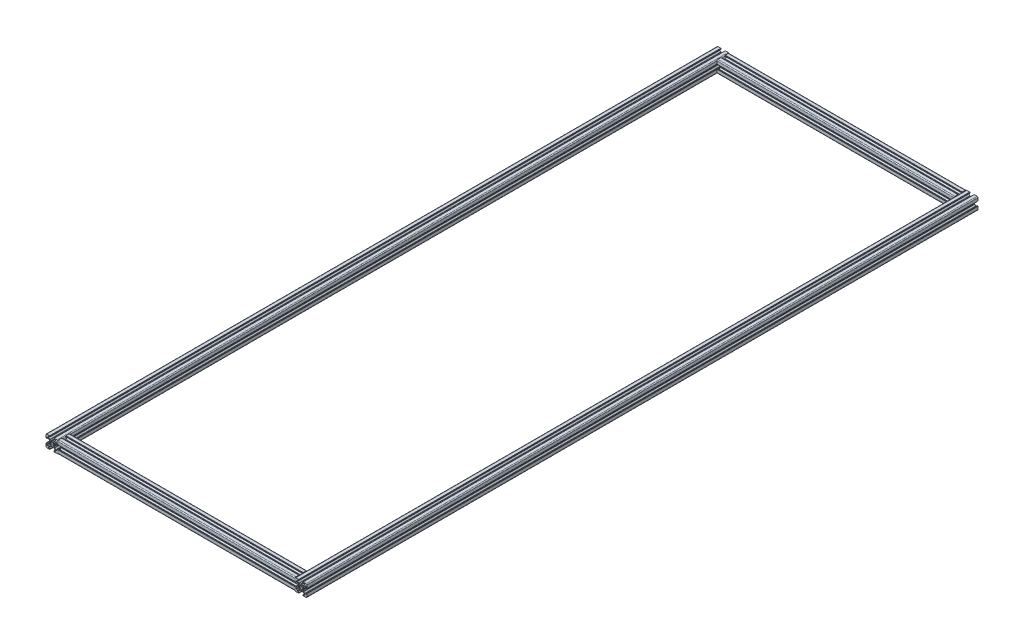
from build123d import *

# Parameters (mm, degrees)
T_SLOT_20X20_1_DEPTH   = 1125
T_SLOT_20X20_1_2_DEPTH = 1125
T_SLOT_20X20_2_DEPTH   = 397.401314794
T_SLOT_20X20_3_DEPTH   = 397.497051185


with BuildPart() as part:
    # Sketch11 → T-slot 20X20(1) (new body)
    with BuildSketch(Plane(origin=(0, 0, 491.029411765), x_dir=(-1, 0, 0), z_dir=(0, 0, -1))):
        with BuildLine():
            Line((5.499785909, -8.498545991), (3.499785223, -8.498545991))
            ThreePointArc((3.499785223, -8.498545991), (3.146231832, -8.644992601), (2.999785223, -8.998545991))
            Line((2.999785223, -8.998545991), (2.999785223, -9.298545991))
            ThreePointArc((2.999785223, -9.298545991), (3.058363866, -9.439967347), (3.199785223, -9.498545991))
            Line((3.199785223, -9.498545991), (3.348917703, -9.498545991))
            ThreePointArc((3.348917703, -9.498545991), (3.490339059, -9.557124635), (3.548917703, -9.698545991))
            Line((3.548917703, -9.698545991), (3.548917703, -9.798898698))
            ThreePointArc((3.548917703, -9.798898698), (3.607496347, -9.940320055), (3.748917703, -9.998898698))
            Line((3.748917703, -9.998898698), (8.50021851, -9.998898698))
            ThreePointArc((8.50021851, -9.998898698), (9.560878681, -9.55955887), (10.00021851, -8.498898698))
            Line((10.00021851, -8.498898698), (10.00021851, -3.748917703))
            ThreePointArc((10.00021851, -3.748917703), (9.941639866, -3.607496347), (9.80021851, -3.548917703))
            Line((9.80021851, -3.548917703), (9.699407618, -3.548917703))
            ThreePointArc((9.699407618, -3.548917703), (9.557986262, -3.490339059), (9.499407618, -3.348917703))
            Line((9.499407618, -3.348917703), (9.499407618, -3.198545506))
            ThreePointArc((9.499407618, -3.198545506), (9.440828975, -3.05712415), (9.299407618, -2.998545506))
            Line((9.299407618, -2.998545506), (8.999407619, -2.998545506))
            ThreePointArc((8.999407619, -2.998545506), (8.645854228, -3.144992116), (8.499407619, -3.498545506))
            Line((8.499407619, -3.498545506), (8.499407619, -5.498575296))
            ThreePointArc((8.499407619, -5.498575296), (8.352961009, -5.852128686), (7.999407619, -5.998575295))
            Line((7.999407619, -5.998575295), (7.267164191, -5.998575295))
            ThreePointArc((7.267164191, -5.998575295), (7.075822118, -5.960514914), (6.913610254, -5.85212814))
            Line((6.913610254, -5.85212814), (4.64584686, -3.584357742))
            ThreePointArc((4.64584686, -3.584357742), (4.537460883, -3.422146257), (4.499400797, -3.230804897))
            Line((4.499400797, -3.230804897), (4.499400797, -0.952160718))
            ThreePointArc((4.499400797, -0.952160718), (4.492585963, -0.900396911), (4.47260588, -0.852160722))
            Line((4.47260588, -0.852160722), (4.037520883, -0.09857136))
            ThreePointArc((4.037520883, -0.09857136), (4.010725966, 0.001428635), (4.037520883, 0.101428631))
            Line((4.037520883, 0.101428631), (4.47260588, 0.855018004))
            ThreePointArc((4.47260588, 0.855018004), (4.492585963, 0.903254193), (4.499400797, 0.955017999))
            Line((4.499400797, 0.955017999), (4.499400797, 3.233299817))
            ThreePointArc((4.499400797, 3.233299817), (4.537461178, 3.42464189), (4.645847952, 3.586853754))
            Line((4.645847952, 3.586853754), (6.91361835, 5.854617148))
            ThreePointArc((6.91361835, 5.854617148), (7.075829835, 5.963003125), (7.267171195, 6.001063211))
            Line((7.267171195, 6.001063211), (7.999407619, 6.001063211))
            ThreePointArc((7.999407619, 6.001063211), (8.352961009, 5.854616602), (8.499407619, 5.501063211))
            Line((8.499407619, 5.501063211), (8.499407619, 3.500665018))
            ThreePointArc((8.499407619, 3.500665018), (8.645854228, 3.147111627), (8.999407619, 3.000665018))
            Line((8.999407619, 3.000665018), (9.299407618, 3.000665018))
            ThreePointArc((9.299407618, 3.000665018), (9.440828975, 3.059243661), (9.499407618, 3.200665018))
            Line((9.499407618, 3.200665018), (9.499407618, 3.348917703))
            ThreePointArc((9.499407618, 3.348917703), (9.557986262, 3.490339059), (9.699407618, 3.548917703))
            Line((9.699407618, 3.548917703), (9.80021851, 3.548917703))
            ThreePointArc((9.80021851, 3.548917703), (9.941639866, 3.607496347), (10.00021851, 3.748917703))
            Line((10.00021851, 3.748917703), (10.00021851, 8.498918098))
            ThreePointArc((10.00021851, 8.498918098), (9.560878681, 9.55957827), (8.50021851, 9.998918098))
            Line((8.50021851, 9.998918098), (3.748917703, 9.998918098))
            ThreePointArc((3.748917703, 9.998918098), (3.607496347, 9.940339455), (3.548917703, 9.798918098))
            Line((3.548917703, 9.798918098), (3.548917703, 9.701076618))
            ThreePointArc((3.548917703, 9.701076618), (3.490339059, 9.559655262), (3.348917703, 9.501076618))
            Line((3.348917703, 9.501076618), (3.199785223, 9.501076618))
            ThreePointArc((3.199785223, 9.501076618), (3.058363866, 9.442497974), (2.999785223, 9.301076618))
            Line((2.999785223, 9.301076618), (2.999785223, 9.001076618))
            ThreePointArc((2.999785223, 9.001076618), (3.146231832, 8.647523228), (3.499785223, 8.501076618))
            Line((3.499785223, 8.501076618), (5.499785909, 8.501076618))
            ThreePointArc((5.499785909, 8.501076618), (5.853339299, 8.354630009), (5.999785909, 8.001076618))
            Line((5.999785909, 8.001076618), (5.999785909, 7.269203309))
            ThreePointArc((5.999785909, 7.269203309), (5.961725527, 7.077861236), (5.853338753, 6.915649372))
            Line((5.853338753, 6.915649372), (3.585209085, 4.647526709))
            ThreePointArc((3.585209085, 4.647526709), (3.4229976, 4.539140732), (3.231656241, 4.501080646))
            Line((3.231656241, 4.501080646), (0.953012714, 4.501080646))
            ThreePointArc((0.953012714, 4.501080646), (0.901248907, 4.494265812), (0.853012718, 4.474285729))
            Line((0.853012718, 4.474285729), (0.099422452, 4.03920021))
            ThreePointArc((0.099422452, 4.03920021), (-0.000577544, 4.012405293), (-0.100577539, 4.03920021))
            Line((-0.100577539, 4.03920021), (-0.854167817, 4.47428573))
            ThreePointArc((-0.854167817, 4.47428573), (-0.902404006, 4.494265812), (-0.954167812, 4.501080646))
            Line((-0.954167812, 4.501080646), (-3.232459322, 4.501080646))
            ThreePointArc((-3.232459322, 4.501080646), (-3.423801395, 4.539141027), (-3.586013258, 4.647527801))
            Line((-3.586013258, 4.647527801), (-5.854146074, 6.915667622))
            ThreePointArc((-5.854146074, 6.915667622), (-5.962532052, 7.077879107), (-6.000592138, 7.269220467))
            Line((-6.000592138, 7.269220467), (-6.000592138, 8.001076618))
            ThreePointArc((-6.000592138, 8.001076618), (-5.854145528, 8.354630009), (-5.500592138, 8.501076618))
            Line((-5.500592138, 8.501076618), (-3.500232358, 8.501076618))
            ThreePointArc((-3.500232358, 8.501076618), (-3.146678968, 8.647523228), (-3.000232358, 9.001076618))
            Line((-3.000232358, 9.001076618), (-3.000232358, 9.301076618))
            ThreePointArc((-3.000232358, 9.301076618), (-3.058811002, 9.442497974), (-3.200232358, 9.501076618))
            Line((-3.200232358, 9.501076618), (-3.348917703, 9.501076618))
            ThreePointArc((-3.348917703, 9.501076618), (-3.490339059, 9.559655262), (-3.548917703, 9.701076618))
            Line((-3.548917703, 9.701076618), (-3.548917703, 9.798918098))
            ThreePointArc((-3.548917703, 9.798918098), (-3.607496347, 9.940339455), (-3.748917703, 9.998918098))
            Line((-3.748917703, 9.998918098), (-8.498466696, 9.998918098))
            ThreePointArc((-8.498466696, 9.998918098), (-9.559126868, 9.55957827), (-9.998466696, 8.498918098))
            Line((-9.998466696, 8.498918098), (-9.998466696, 3.748917703))
            ThreePointArc((-9.998466696, 3.748917703), (-9.939888052, 3.607496347), (-9.798466696, 3.548917703))
            Line((-9.798466696, 3.548917703), (-9.699890154, 3.548917703))
            ThreePointArc((-9.699890154, 3.548917703), (-9.558468798, 3.490339059), (-9.499890154, 3.348917703))
            Line((-9.499890154, 3.348917703), (-9.499890154, 3.200665018))
            ThreePointArc((-9.499890154, 3.200665018), (-9.441311511, 3.059243661), (-9.299890154, 3.000665018))
            Line((-9.299890154, 3.000665018), (-8.999890154, 3.000665018))
            ThreePointArc((-8.999890154, 3.000665018), (-8.646336764, 3.147111627), (-8.499890154, 3.500665018))
            Line((-8.499890154, 3.500665018), (-8.499890154, 5.501063211))
            ThreePointArc((-8.499890154, 5.501063211), (-8.353443545, 5.854616602), (-7.999890154, 6.001063211))
            Line((-7.999890154, 6.001063211), (-7.26792762, 6.001063211))
            ThreePointArc((-7.26792762, 6.001063211), (-7.076585548, 5.96300283), (-6.914373684, 5.854616056))
            Line((-6.914373684, 5.854616056), (-4.646707794, 3.586943162))
            ThreePointArc((-4.646707794, 3.586943162), (-4.538321817, 3.424731677), (-4.500261731, 3.233390317))
            Line((-4.500261731, 3.233390317), (-4.500261731, 0.955009441))
            ThreePointArc((-4.500261731, 0.955009441), (-4.493446896, 0.903245635), (-4.473466814, 0.855009445))
            Line((-4.473466814, 0.855009445), (-4.03838182, 0.101420088))
            ThreePointArc((-4.03838182, 0.101420088), (-4.011586903, 0.001420093), (-4.038381819, -0.098579903))
            Line((-4.038381819, -0.098579903), (-4.473466814, -0.852169272))
            ThreePointArc((-4.473466814, -0.852169272), (-4.493446897, -0.90040546), (-4.500261731, -0.952169266))
            Line((-4.500261731, -0.952169266), (-4.500261731, -3.230811901))
            ThreePointArc((-4.500261731, -3.230811901), (-4.538322112, -3.422153974), (-4.646708886, -3.584365838))
            Line((-4.646708886, -3.584365838), (-6.914479284, -5.852129232))
            ThreePointArc((-6.914479284, -5.852129232), (-7.076690769, -5.960515209), (-7.268032129, -5.998575295))
            Line((-7.268032129, -5.998575295), (-7.999890154, -5.998575295))
            ThreePointArc((-7.999890154, -5.998575295), (-8.353443545, -5.852128686), (-8.499890154, -5.498575295))
            Line((-8.499890154, -5.498575295), (-8.499890154, -3.498545506))
            ThreePointArc((-8.499890154, -3.498545506), (-8.646336764, -3.144992116), (-8.999890154, -2.998545506))
            Line((-8.999890154, -2.998545506), (-9.299890154, -2.998545506))
            ThreePointArc((-9.299890154, -2.998545506), (-9.441311511, -3.05712415), (-9.499890154, -3.198545506))
            Line((-9.499890154, -3.198545506), (-9.499890154, -3.348917703))
            ThreePointArc((-9.499890154, -3.348917703), (-9.558468798, -3.490339059), (-9.699890154, -3.548917703))
            Line((-9.699890154, -3.548917703), (-9.798466696, -3.548917703))
            ThreePointArc((-9.798466696, -3.548917703), (-9.939888052, -3.607496347), (-9.998466696, -3.748917703))
            Line((-9.998466696, -3.748917703), (-9.998466696, -8.498898698))
            ThreePointArc((-9.998466696, -8.498898698), (-9.559126868, -9.55955887), (-8.498466696, -9.998898698))
            Line((-8.498466696, -9.998898698), (-3.748917703, -9.998898698))
            ThreePointArc((-3.748917703, -9.998898698), (-3.607496347, -9.940320055), (-3.548917703, -9.798898698))
            Line((-3.548917703, -9.798898698), (-3.548917703, -9.698545991))
            ThreePointArc((-3.548917703, -9.698545991), (-3.490339059, -9.557124635), (-3.348917703, -9.498545991))
            Line((-3.348917703, -9.498545991), (-3.200232358, -9.498545991))
            ThreePointArc((-3.200232358, -9.498545991), (-3.058811002, -9.439967347), (-3.000232358, -9.298545991))
            Line((-3.000232358, -9.298545991), (-3.000232358, -8.998545991))
            ThreePointArc((-3.000232358, -8.998545991), (-3.146678968, -8.644992601), (-3.500232358, -8.498545991))
            Line((-3.500232358, -8.498545991), (-5.500592138, -8.498545991))
            ThreePointArc((-5.500592138, -8.498545991), (-5.854145528, -8.352099382), (-6.000592138, -7.998545991))
            Line((-6.000592138, -7.998545991), (-6.000592138, -7.266660688))
            ThreePointArc((-6.000592138, -7.266660688), (-5.962531756, -7.075318615), (-5.854144982, -6.913106751))
            Line((-5.854144982, -6.913106751), (-3.58639624, -4.645365013))
            ThreePointArc((-3.58639624, -4.645365013), (-3.424184755, -4.536979036), (-3.232843395, -4.49891895))
            Line((-3.232843395, -4.49891895), (-0.954199096, -4.49891895))
            ThreePointArc((-0.954199096, -4.49891895), (-0.90243529, -4.492104116), (-0.854199101, -4.472124033))
            Line((-0.854199101, -4.472124033), (-0.100608835, -4.037038514))
            ThreePointArc((-0.100608835, -4.037038514), (-0.00060884, -4.010243598), (0.099391156, -4.037038514))
            Line((0.099391156, -4.037038514), (0.852981433, -4.472124033))
            ThreePointArc((0.852981433, -4.472124033), (0.901217622, -4.492104116), (0.952981428, -4.49891895))
            Line((0.952981428, -4.49891895), (3.232022111, -4.49891895))
            ThreePointArc((3.232022111, -4.49891895), (3.423364184, -4.536979331), (3.585576047, -4.645366105))
            Line((3.585576047, -4.645366105), (5.853339845, -6.913136907))
            ThreePointArc((5.853339845, -6.913136907), (5.961725823, -7.075348392), (5.999785909, -7.266689752))
            Line((5.999785909, -7.266689752), (5.999785909, -7.998545991))
            ThreePointArc((5.999785909, -7.998545991), (5.853339299, -8.352099382), (5.499785909, -8.498545991))
        make_face()
        with BuildLine():
            Line((2.99144723, 1.909465981), (2.444531068, 1.257791687))
            ThreePointArc((2.444531068, 1.257791687), (2.749140242, -3.06e-07), (2.444530789, -1.257792231))
            Line((2.444530789, -1.257792231), (2.991447018, -1.909466314))
            ThreePointArc((2.991447018, -1.909466314), (2.511126206, -2.50780024), (1.913429408, -2.988913643))
            Line((1.913429408, -2.988913643), (1.257791806, -2.444531007))
            ThreePointArc((1.257791806, -2.444531007), (-3.06e-07, -2.749140242), (-1.25779235, -2.444530727))
            Line((-1.25779235, -2.444530727), (-1.913495818, -2.988871128))
            ThreePointArc((-1.913495818, -2.988871128), (-2.511154205, -2.507772203), (-2.99144723, -1.909465981))
            Line((-2.99144723, -1.909465981), (-2.444531068, -1.257791687))
            ThreePointArc((-2.444531068, -1.257791687), (-2.749140242, 3.06e-07), (-2.444530789, 1.257792231))
            Line((-2.444530789, 1.257792231), (-2.991447018, 1.909466314))
            ThreePointArc((-2.991447018, 1.909466314), (-2.511126206, 2.50780024), (-1.913429408, 2.988913643))
            Line((-1.913429408, 2.988913643), (-1.257791806, 2.444531007))
            ThreePointArc((-1.257791806, 2.444531007), (-4.0323e-05, 2.749140242), (1.257720096, 2.444567903))
            Line((1.257720096, 2.444567903), (1.91342974, 2.98891343))
            ThreePointArc((1.91342974, 2.98891343), (2.511126484, 2.507799961), (2.99144723, 1.909465981))
        make_face(mode=Mode.SUBTRACT)
    extrude(amount=T_SLOT_20X20_1_DEPTH)


with BuildPart() as body_2:
    # Sketch11 on segment 2 (carried to segment 2) → T-slot 20X20_1 2 (new body)
    with BuildSketch(Plane(origin=(417.4, 0, 491.029411765), x_dir=(-1, 0, 0), z_dir=(0, 0, -1))):
        with BuildLine():
            Line((5.499785909, -8.498545991), (3.499785223, -8.498545991))
            ThreePointArc((3.499785223, -8.498545991), (3.146231832, -8.644992601), (2.999785223, -8.998545991))
            Line((2.999785223, -8.998545991), (2.999785223, -9.298545991))
            ThreePointArc((2.999785223, -9.298545991), (3.058363866, -9.439967347), (3.199785223, -9.498545991))
            Line((3.199785223, -9.498545991), (3.348917703, -9.498545991))
            ThreePointArc((3.348917703, -9.498545991), (3.490339059, -9.557124635), (3.548917703, -9.698545991))
            Line((3.548917703, -9.698545991), (3.548917703, -9.798898698))
            ThreePointArc((3.548917703, -9.798898698), (3.607496347, -9.940320055), (3.748917703, -9.998898698))
            Line((3.748917703, -9.998898698), (8.50021851, -9.998898698))
            ThreePointArc((8.50021851, -9.998898698), (9.560878681, -9.55955887), (10.00021851, -8.498898698))
            Line((10.00021851, -8.498898698), (10.00021851, -3.748917703))
            ThreePointArc((10.00021851, -3.748917703), (9.941639866, -3.607496347), (9.80021851, -3.548917703))
            Line((9.80021851, -3.548917703), (9.699407618, -3.548917703))
            ThreePointArc((9.699407618, -3.548917703), (9.557986262, -3.490339059), (9.499407618, -3.348917703))
            Line((9.499407618, -3.348917703), (9.499407618, -3.198545506))
            ThreePointArc((9.499407618, -3.198545506), (9.440828975, -3.05712415), (9.299407618, -2.998545506))
            Line((9.299407618, -2.998545506), (8.999407619, -2.998545506))
            ThreePointArc((8.999407619, -2.998545506), (8.645854228, -3.144992116), (8.499407619, -3.498545506))
            Line((8.499407619, -3.498545506), (8.499407619, -5.498575296))
            ThreePointArc((8.499407619, -5.498575296), (8.352961009, -5.852128686), (7.999407619, -5.998575295))
            Line((7.999407619, -5.998575295), (7.267164191, -5.998575295))
            ThreePointArc((7.267164191, -5.998575295), (7.075822118, -5.960514914), (6.913610254, -5.85212814))
            Line((6.913610254, -5.85212814), (4.64584686, -3.584357742))
            ThreePointArc((4.64584686, -3.584357742), (4.537460883, -3.422146257), (4.499400797, -3.230804897))
            Line((4.499400797, -3.230804897), (4.499400797, -0.952160718))
            ThreePointArc((4.499400797, -0.952160718), (4.492585963, -0.900396911), (4.47260588, -0.852160722))
            Line((4.47260588, -0.852160722), (4.037520883, -0.09857136))
            ThreePointArc((4.037520883, -0.09857136), (4.010725966, 0.001428635), (4.037520883, 0.101428631))
            Line((4.037520883, 0.101428631), (4.47260588, 0.855018004))
            ThreePointArc((4.47260588, 0.855018004), (4.492585963, 0.903254193), (4.499400797, 0.955017999))
            Line((4.499400797, 0.955017999), (4.499400797, 3.233299817))
            ThreePointArc((4.499400797, 3.233299817), (4.537461178, 3.42464189), (4.645847952, 3.586853754))
            Line((4.645847952, 3.586853754), (6.91361835, 5.854617148))
            ThreePointArc((6.91361835, 5.854617148), (7.075829835, 5.963003125), (7.267171195, 6.001063211))
            Line((7.267171195, 6.001063211), (7.999407619, 6.001063211))
            ThreePointArc((7.999407619, 6.001063211), (8.352961009, 5.854616602), (8.499407619, 5.501063211))
            Line((8.499407619, 5.501063211), (8.499407619, 3.500665018))
            ThreePointArc((8.499407619, 3.500665018), (8.645854228, 3.147111627), (8.999407619, 3.000665018))
            Line((8.999407619, 3.000665018), (9.299407618, 3.000665018))
            ThreePointArc((9.299407618, 3.000665018), (9.440828975, 3.059243661), (9.499407618, 3.200665018))
            Line((9.499407618, 3.200665018), (9.499407618, 3.348917703))
            ThreePointArc((9.499407618, 3.348917703), (9.557986262, 3.490339059), (9.699407618, 3.548917703))
            Line((9.699407618, 3.548917703), (9.80021851, 3.548917703))
            ThreePointArc((9.80021851, 3.548917703), (9.941639866, 3.607496347), (10.00021851, 3.748917703))
            Line((10.00021851, 3.748917703), (10.00021851, 8.498918098))
            ThreePointArc((10.00021851, 8.498918098), (9.560878681, 9.55957827), (8.50021851, 9.998918098))
            Line((8.50021851, 9.998918098), (3.748917703, 9.998918098))
            ThreePointArc((3.748917703, 9.998918098), (3.607496347, 9.940339455), (3.548917703, 9.798918098))
            Line((3.548917703, 9.798918098), (3.548917703, 9.701076618))
            ThreePointArc((3.548917703, 9.701076618), (3.490339059, 9.559655262), (3.348917703, 9.501076618))
            Line((3.348917703, 9.501076618), (3.199785223, 9.501076618))
            ThreePointArc((3.199785223, 9.501076618), (3.058363866, 9.442497974), (2.999785223, 9.301076618))
            Line((2.999785223, 9.301076618), (2.999785223, 9.001076618))
            ThreePointArc((2.999785223, 9.001076618), (3.146231832, 8.647523228), (3.499785223, 8.501076618))
            Line((3.499785223, 8.501076618), (5.499785909, 8.501076618))
            ThreePointArc((5.499785909, 8.501076618), (5.853339299, 8.354630009), (5.999785909, 8.001076618))
            Line((5.999785909, 8.001076618), (5.999785909, 7.269203309))
            ThreePointArc((5.999785909, 7.269203309), (5.961725527, 7.077861236), (5.853338753, 6.915649372))
            Line((5.853338753, 6.915649372), (3.585209085, 4.647526709))
            ThreePointArc((3.585209085, 4.647526709), (3.4229976, 4.539140732), (3.231656241, 4.501080646))
            Line((3.231656241, 4.501080646), (0.953012714, 4.501080646))
            ThreePointArc((0.953012714, 4.501080646), (0.901248907, 4.494265812), (0.853012718, 4.474285729))
            Line((0.853012718, 4.474285729), (0.099422452, 4.03920021))
            ThreePointArc((0.099422452, 4.03920021), (-0.000577544, 4.012405293), (-0.100577539, 4.03920021))
            Line((-0.100577539, 4.03920021), (-0.854167817, 4.47428573))
            ThreePointArc((-0.854167817, 4.47428573), (-0.902404006, 4.494265812), (-0.954167812, 4.501080646))
            Line((-0.954167812, 4.501080646), (-3.232459322, 4.501080646))
            ThreePointArc((-3.232459322, 4.501080646), (-3.423801395, 4.539141027), (-3.586013258, 4.647527801))
            Line((-3.586013258, 4.647527801), (-5.854146074, 6.915667622))
            ThreePointArc((-5.854146074, 6.915667622), (-5.962532052, 7.077879107), (-6.000592138, 7.269220467))
            Line((-6.000592138, 7.269220467), (-6.000592138, 8.001076618))
            ThreePointArc((-6.000592138, 8.001076618), (-5.854145528, 8.354630009), (-5.500592138, 8.501076618))
            Line((-5.500592138, 8.501076618), (-3.500232358, 8.501076618))
            ThreePointArc((-3.500232358, 8.501076618), (-3.146678968, 8.647523228), (-3.000232358, 9.001076618))
            Line((-3.000232358, 9.001076618), (-3.000232358, 9.301076618))
            ThreePointArc((-3.000232358, 9.301076618), (-3.058811002, 9.442497974), (-3.200232358, 9.501076618))
            Line((-3.200232358, 9.501076618), (-3.348917703, 9.501076618))
            ThreePointArc((-3.348917703, 9.501076618), (-3.490339059, 9.559655262), (-3.548917703, 9.701076618))
            Line((-3.548917703, 9.701076618), (-3.548917703, 9.798918098))
            ThreePointArc((-3.548917703, 9.798918098), (-3.607496347, 9.940339455), (-3.748917703, 9.998918098))
            Line((-3.748917703, 9.998918098), (-8.498466696, 9.998918098))
            ThreePointArc((-8.498466696, 9.998918098), (-9.559126868, 9.55957827), (-9.998466696, 8.498918098))
            Line((-9.998466696, 8.498918098), (-9.998466696, 3.748917703))
            ThreePointArc((-9.998466696, 3.748917703), (-9.939888052, 3.607496347), (-9.798466696, 3.548917703))
            Line((-9.798466696, 3.548917703), (-9.699890154, 3.548917703))
            ThreePointArc((-9.699890154, 3.548917703), (-9.558468798, 3.490339059), (-9.499890154, 3.348917703))
            Line((-9.499890154, 3.348917703), (-9.499890154, 3.200665018))
            ThreePointArc((-9.499890154, 3.200665018), (-9.441311511, 3.059243661), (-9.299890154, 3.000665018))
            Line((-9.299890154, 3.000665018), (-8.999890154, 3.000665018))
            ThreePointArc((-8.999890154, 3.000665018), (-8.646336764, 3.147111627), (-8.499890154, 3.500665018))
            Line((-8.499890154, 3.500665018), (-8.499890154, 5.501063211))
            ThreePointArc((-8.499890154, 5.501063211), (-8.353443545, 5.854616602), (-7.999890154, 6.001063211))
            Line((-7.999890154, 6.001063211), (-7.26792762, 6.001063211))
            ThreePointArc((-7.26792762, 6.001063211), (-7.076585548, 5.96300283), (-6.914373684, 5.854616056))
            Line((-6.914373684, 5.854616056), (-4.646707794, 3.586943162))
            ThreePointArc((-4.646707794, 3.586943162), (-4.538321817, 3.424731677), (-4.500261731, 3.233390317))
            Line((-4.500261731, 3.233390317), (-4.500261731, 0.955009441))
            ThreePointArc((-4.500261731, 0.955009441), (-4.493446896, 0.903245635), (-4.473466814, 0.855009445))
            Line((-4.473466814, 0.855009445), (-4.03838182, 0.101420088))
            ThreePointArc((-4.03838182, 0.101420088), (-4.011586903, 0.001420093), (-4.038381819, -0.098579903))
            Line((-4.038381819, -0.098579903), (-4.473466814, -0.852169272))
            ThreePointArc((-4.473466814, -0.852169272), (-4.493446897, -0.90040546), (-4.500261731, -0.952169266))
            Line((-4.500261731, -0.952169266), (-4.500261731, -3.230811901))
            ThreePointArc((-4.500261731, -3.230811901), (-4.538322112, -3.422153974), (-4.646708886, -3.584365838))
            Line((-4.646708886, -3.584365838), (-6.914479284, -5.852129232))
            ThreePointArc((-6.914479284, -5.852129232), (-7.076690769, -5.960515209), (-7.268032129, -5.998575295))
            Line((-7.268032129, -5.998575295), (-7.999890154, -5.998575295))
            ThreePointArc((-7.999890154, -5.998575295), (-8.353443545, -5.852128686), (-8.499890154, -5.498575295))
            Line((-8.499890154, -5.498575295), (-8.499890154, -3.498545506))
            ThreePointArc((-8.499890154, -3.498545506), (-8.646336764, -3.144992116), (-8.999890154, -2.998545506))
            Line((-8.999890154, -2.998545506), (-9.299890154, -2.998545506))
            ThreePointArc((-9.299890154, -2.998545506), (-9.441311511, -3.05712415), (-9.499890154, -3.198545506))
            Line((-9.499890154, -3.198545506), (-9.499890154, -3.348917703))
            ThreePointArc((-9.499890154, -3.348917703), (-9.558468798, -3.490339059), (-9.699890154, -3.548917703))
            Line((-9.699890154, -3.548917703), (-9.798466696, -3.548917703))
            ThreePointArc((-9.798466696, -3.548917703), (-9.939888052, -3.607496347), (-9.998466696, -3.748917703))
            Line((-9.998466696, -3.748917703), (-9.998466696, -8.498898698))
            ThreePointArc((-9.998466696, -8.498898698), (-9.559126868, -9.55955887), (-8.498466696, -9.998898698))
            Line((-8.498466696, -9.998898698), (-3.748917703, -9.998898698))
            ThreePointArc((-3.748917703, -9.998898698), (-3.607496347, -9.940320055), (-3.548917703, -9.798898698))
            Line((-3.548917703, -9.798898698), (-3.548917703, -9.698545991))
            ThreePointArc((-3.548917703, -9.698545991), (-3.490339059, -9.557124635), (-3.348917703, -9.498545991))
            Line((-3.348917703, -9.498545991), (-3.200232358, -9.498545991))
            ThreePointArc((-3.200232358, -9.498545991), (-3.058811002, -9.439967347), (-3.000232358, -9.298545991))
            Line((-3.000232358, -9.298545991), (-3.000232358, -8.998545991))
            ThreePointArc((-3.000232358, -8.998545991), (-3.146678968, -8.644992601), (-3.500232358, -8.498545991))
            Line((-3.500232358, -8.498545991), (-5.500592138, -8.498545991))
            ThreePointArc((-5.500592138, -8.498545991), (-5.854145528, -8.352099382), (-6.000592138, -7.998545991))
            Line((-6.000592138, -7.998545991), (-6.000592138, -7.266660688))
            ThreePointArc((-6.000592138, -7.266660688), (-5.962531756, -7.075318615), (-5.854144982, -6.913106751))
            Line((-5.854144982, -6.913106751), (-3.58639624, -4.645365013))
            ThreePointArc((-3.58639624, -4.645365013), (-3.424184755, -4.536979036), (-3.232843395, -4.49891895))
            Line((-3.232843395, -4.49891895), (-0.954199096, -4.49891895))
            ThreePointArc((-0.954199096, -4.49891895), (-0.90243529, -4.492104116), (-0.854199101, -4.472124033))
            Line((-0.854199101, -4.472124033), (-0.100608835, -4.037038514))
            ThreePointArc((-0.100608835, -4.037038514), (-0.00060884, -4.010243598), (0.099391156, -4.037038514))
            Line((0.099391156, -4.037038514), (0.852981433, -4.472124033))
            ThreePointArc((0.852981433, -4.472124033), (0.901217622, -4.492104116), (0.952981428, -4.49891895))
            Line((0.952981428, -4.49891895), (3.232022111, -4.49891895))
            ThreePointArc((3.232022111, -4.49891895), (3.423364184, -4.536979331), (3.585576047, -4.645366105))
            Line((3.585576047, -4.645366105), (5.853339845, -6.913136907))
            ThreePointArc((5.853339845, -6.913136907), (5.961725823, -7.075348392), (5.999785909, -7.266689752))
            Line((5.999785909, -7.266689752), (5.999785909, -7.998545991))
            ThreePointArc((5.999785909, -7.998545991), (5.853339299, -8.352099382), (5.499785909, -8.498545991))
        make_face()
        with BuildLine():
            Line((2.99144723, 1.909465981), (2.444531068, 1.257791687))
            ThreePointArc((2.444531068, 1.257791687), (2.749140242, -3.06e-07), (2.444530789, -1.257792231))
            Line((2.444530789, -1.257792231), (2.991447018, -1.909466314))
            ThreePointArc((2.991447018, -1.909466314), (2.511126206, -2.50780024), (1.913429408, -2.988913643))
            Line((1.913429408, -2.988913643), (1.257791806, -2.444531007))
            ThreePointArc((1.257791806, -2.444531007), (-3.06e-07, -2.749140242), (-1.25779235, -2.444530727))
            Line((-1.25779235, -2.444530727), (-1.913495818, -2.988871128))
            ThreePointArc((-1.913495818, -2.988871128), (-2.511154205, -2.507772203), (-2.99144723, -1.909465981))
            Line((-2.99144723, -1.909465981), (-2.444531068, -1.257791687))
            ThreePointArc((-2.444531068, -1.257791687), (-2.749140242, 3.06e-07), (-2.444530789, 1.257792231))
            Line((-2.444530789, 1.257792231), (-2.991447018, 1.909466314))
            ThreePointArc((-2.991447018, 1.909466314), (-2.511126206, 2.50780024), (-1.913429408, 2.988913643))
            Line((-1.913429408, 2.988913643), (-1.257791806, 2.444531007))
            ThreePointArc((-1.257791806, 2.444531007), (-4.0323e-05, 2.749140242), (1.257720096, 2.444567903))
            Line((1.257720096, 2.444567903), (1.91342974, 2.98891343))
            ThreePointArc((1.91342974, 2.98891343), (2.511126484, 2.507799961), (2.99144723, 1.909465981))
        make_face(mode=Mode.SUBTRACT)
    extrude(amount=T_SLOT_20X20_1_2_DEPTH)


with BuildPart() as body_3:
    # Sketch13 → T-slot 20X20(2) (new body)
    with BuildSketch(Plane(origin=(9.998466696, 0, -623.970588235), x_dir=(0, 0, -1), z_dir=(1, 0, 0))):
        with BuildLine():
            Line((5.499785909, -8.498545991), (3.499785223, -8.498545991))
            ThreePointArc((3.499785223, -8.498545991), (3.146231832, -8.644992601), (2.999785223, -8.998545991))
            Line((2.999785223, -8.998545991), (2.999785223, -9.298545991))
            ThreePointArc((2.999785223, -9.298545991), (3.058363866, -9.439967347), (3.199785223, -9.498545991))
            Line((3.199785223, -9.498545991), (3.348917703, -9.498545991))
            ThreePointArc((3.348917703, -9.498545991), (3.490339059, -9.557124635), (3.548917703, -9.698545991))
            Line((3.548917703, -9.698545991), (3.548917703, -9.798898698))
            ThreePointArc((3.548917703, -9.798898698), (3.607496347, -9.940320055), (3.748917703, -9.998898698))
            Line((3.748917703, -9.998898698), (8.50021851, -9.998898698))
            ThreePointArc((8.50021851, -9.998898698), (9.560878681, -9.55955887), (10.00021851, -8.498898698))
            Line((10.00021851, -8.498898698), (10.00021851, -3.748917703))
            ThreePointArc((10.00021851, -3.748917703), (9.941639866, -3.607496347), (9.80021851, -3.548917703))
            Line((9.80021851, -3.548917703), (9.699407618, -3.548917703))
            ThreePointArc((9.699407618, -3.548917703), (9.557986262, -3.490339059), (9.499407618, -3.348917703))
            Line((9.499407618, -3.348917703), (9.499407618, -3.198545506))
            ThreePointArc((9.499407618, -3.198545506), (9.440828975, -3.05712415), (9.299407618, -2.998545506))
            Line((9.299407618, -2.998545506), (8.999407619, -2.998545506))
            ThreePointArc((8.999407619, -2.998545506), (8.645854228, -3.144992116), (8.499407619, -3.498545506))
            Line((8.499407619, -3.498545506), (8.499407619, -5.498575296))
            ThreePointArc((8.499407619, -5.498575296), (8.352961009, -5.852128686), (7.999407619, -5.998575295))
            Line((7.999407619, -5.998575295), (7.267164191, -5.998575295))
            ThreePointArc((7.267164191, -5.998575295), (7.075822118, -5.960514914), (6.913610254, -5.85212814))
            Line((6.913610254, -5.85212814), (4.64584686, -3.584357742))
            ThreePointArc((4.64584686, -3.584357742), (4.537460883, -3.422146257), (4.499400797, -3.230804897))
            Line((4.499400797, -3.230804897), (4.499400797, -0.952160718))
            ThreePointArc((4.499400797, -0.952160718), (4.492585963, -0.900396911), (4.47260588, -0.852160722))
            Line((4.47260588, -0.852160722), (4.037520883, -0.09857136))
            ThreePointArc((4.037520883, -0.09857136), (4.010725966, 0.001428635), (4.037520883, 0.101428631))
            Line((4.037520883, 0.101428631), (4.47260588, 0.855018004))
            ThreePointArc((4.47260588, 0.855018004), (4.492585963, 0.903254193), (4.499400797, 0.955017999))
            Line((4.499400797, 0.955017999), (4.499400797, 3.233299817))
            ThreePointArc((4.499400797, 3.233299817), (4.537461178, 3.42464189), (4.645847952, 3.586853754))
            Line((4.645847952, 3.586853754), (6.91361835, 5.854617148))
            ThreePointArc((6.91361835, 5.854617148), (7.075829835, 5.963003125), (7.267171195, 6.001063211))
            Line((7.267171195, 6.001063211), (7.999407619, 6.001063211))
            ThreePointArc((7.999407619, 6.001063211), (8.352961009, 5.854616602), (8.499407619, 5.501063211))
            Line((8.499407619, 5.501063211), (8.499407619, 3.500665018))
            ThreePointArc((8.499407619, 3.500665018), (8.645854228, 3.147111627), (8.999407619, 3.000665018))
            Line((8.999407619, 3.000665018), (9.299407618, 3.000665018))
            ThreePointArc((9.299407618, 3.000665018), (9.440828975, 3.059243661), (9.499407618, 3.200665018))
            Line((9.499407618, 3.200665018), (9.499407618, 3.348917703))
            ThreePointArc((9.499407618, 3.348917703), (9.557986262, 3.490339059), (9.699407618, 3.548917703))
            Line((9.699407618, 3.548917703), (9.80021851, 3.548917703))
            ThreePointArc((9.80021851, 3.548917703), (9.941639866, 3.607496347), (10.00021851, 3.748917703))
            Line((10.00021851, 3.748917703), (10.00021851, 8.498918098))
            ThreePointArc((10.00021851, 8.498918098), (9.560878681, 9.55957827), (8.50021851, 9.998918098))
            Line((8.50021851, 9.998918098), (3.748917703, 9.998918098))
            ThreePointArc((3.748917703, 9.998918098), (3.607496347, 9.940339455), (3.548917703, 9.798918098))
            Line((3.548917703, 9.798918098), (3.548917703, 9.701076618))
            ThreePointArc((3.548917703, 9.701076618), (3.490339059, 9.559655262), (3.348917703, 9.501076618))
            Line((3.348917703, 9.501076618), (3.199785223, 9.501076618))
            ThreePointArc((3.199785223, 9.501076618), (3.058363866, 9.442497974), (2.999785223, 9.301076618))
            Line((2.999785223, 9.301076618), (2.999785223, 9.001076618))
            ThreePointArc((2.999785223, 9.001076618), (3.146231832, 8.647523228), (3.499785223, 8.501076618))
            Line((3.499785223, 8.501076618), (5.499785909, 8.501076618))
            ThreePointArc((5.499785909, 8.501076618), (5.853339299, 8.354630009), (5.999785909, 8.001076618))
            Line((5.999785909, 8.001076618), (5.999785909, 7.269203309))
            ThreePointArc((5.999785909, 7.269203309), (5.961725527, 7.077861236), (5.853338753, 6.915649372))
            Line((5.853338753, 6.915649372), (3.585209085, 4.647526709))
            ThreePointArc((3.585209085, 4.647526709), (3.4229976, 4.539140732), (3.231656241, 4.501080646))
            Line((3.231656241, 4.501080646), (0.953012714, 4.501080646))
            ThreePointArc((0.953012714, 4.501080646), (0.901248907, 4.494265812), (0.853012718, 4.474285729))
            Line((0.853012718, 4.474285729), (0.099422452, 4.03920021))
            ThreePointArc((0.099422452, 4.03920021), (-0.000577544, 4.012405293), (-0.100577539, 4.03920021))
            Line((-0.100577539, 4.03920021), (-0.854167817, 4.47428573))
            ThreePointArc((-0.854167817, 4.47428573), (-0.902404006, 4.494265812), (-0.954167812, 4.501080646))
            Line((-0.954167812, 4.501080646), (-3.232459322, 4.501080646))
            ThreePointArc((-3.232459322, 4.501080646), (-3.423801395, 4.539141027), (-3.586013258, 4.647527801))
            Line((-3.586013258, 4.647527801), (-5.854146074, 6.915667622))
            ThreePointArc((-5.854146074, 6.915667622), (-5.962532052, 7.077879107), (-6.000592138, 7.269220467))
            Line((-6.000592138, 7.269220467), (-6.000592138, 8.001076618))
            ThreePointArc((-6.000592138, 8.001076618), (-5.854145528, 8.354630009), (-5.500592138, 8.501076618))
            Line((-5.500592138, 8.501076618), (-3.500232358, 8.501076618))
            ThreePointArc((-3.500232358, 8.501076618), (-3.146678968, 8.647523228), (-3.000232358, 9.001076618))
            Line((-3.000232358, 9.001076618), (-3.000232358, 9.301076618))
            ThreePointArc((-3.000232358, 9.301076618), (-3.058811002, 9.442497974), (-3.200232358, 9.501076618))
            Line((-3.200232358, 9.501076618), (-3.348917703, 9.501076618))
            ThreePointArc((-3.348917703, 9.501076618), (-3.490339059, 9.559655262), (-3.548917703, 9.701076618))
            Line((-3.548917703, 9.701076618), (-3.548917703, 9.798918098))
            ThreePointArc((-3.548917703, 9.798918098), (-3.607496347, 9.940339455), (-3.748917703, 9.998918098))
            Line((-3.748917703, 9.998918098), (-8.498466696, 9.998918098))
            ThreePointArc((-8.498466696, 9.998918098), (-9.559126868, 9.55957827), (-9.998466696, 8.498918098))
            Line((-9.998466696, 8.498918098), (-9.998466696, 3.748917703))
            ThreePointArc((-9.998466696, 3.748917703), (-9.939888052, 3.607496347), (-9.798466696, 3.548917703))
            Line((-9.798466696, 3.548917703), (-9.699890154, 3.548917703))
            ThreePointArc((-9.699890154, 3.548917703), (-9.558468798, 3.490339059), (-9.499890154, 3.348917703))
            Line((-9.499890154, 3.348917703), (-9.499890154, 3.200665018))
            ThreePointArc((-9.499890154, 3.200665018), (-9.441311511, 3.059243661), (-9.299890154, 3.000665018))
            Line((-9.299890154, 3.000665018), (-8.999890154, 3.000665018))
            ThreePointArc((-8.999890154, 3.000665018), (-8.646336764, 3.147111627), (-8.499890154, 3.500665018))
            Line((-8.499890154, 3.500665018), (-8.499890154, 5.501063211))
            ThreePointArc((-8.499890154, 5.501063211), (-8.353443545, 5.854616602), (-7.999890154, 6.001063211))
            Line((-7.999890154, 6.001063211), (-7.26792762, 6.001063211))
            ThreePointArc((-7.26792762, 6.001063211), (-7.076585548, 5.96300283), (-6.914373684, 5.854616056))
            Line((-6.914373684, 5.854616056), (-4.646707794, 3.586943162))
            ThreePointArc((-4.646707794, 3.586943162), (-4.538321817, 3.424731677), (-4.500261731, 3.233390317))
            Line((-4.500261731, 3.233390317), (-4.500261731, 0.955009441))
            ThreePointArc((-4.500261731, 0.955009441), (-4.493446896, 0.903245635), (-4.473466814, 0.855009445))
            Line((-4.473466814, 0.855009445), (-4.03838182, 0.101420088))
            ThreePointArc((-4.03838182, 0.101420088), (-4.011586903, 0.001420093), (-4.038381819, -0.098579903))
            Line((-4.038381819, -0.098579903), (-4.473466814, -0.852169272))
            ThreePointArc((-4.473466814, -0.852169272), (-4.493446897, -0.90040546), (-4.500261731, -0.952169266))
            Line((-4.500261731, -0.952169266), (-4.500261731, -3.230811901))
            ThreePointArc((-4.500261731, -3.230811901), (-4.538322112, -3.422153974), (-4.646708886, -3.584365838))
            Line((-4.646708886, -3.584365838), (-6.914479284, -5.852129232))
            ThreePointArc((-6.914479284, -5.852129232), (-7.076690769, -5.960515209), (-7.268032129, -5.998575295))
            Line((-7.268032129, -5.998575295), (-7.999890154, -5.998575295))
            ThreePointArc((-7.999890154, -5.998575295), (-8.353443545, -5.852128686), (-8.499890154, -5.498575295))
            Line((-8.499890154, -5.498575295), (-8.499890154, -3.498545506))
            ThreePointArc((-8.499890154, -3.498545506), (-8.646336764, -3.144992116), (-8.999890154, -2.998545506))
            Line((-8.999890154, -2.998545506), (-9.299890154, -2.998545506))
            ThreePointArc((-9.299890154, -2.998545506), (-9.441311511, -3.05712415), (-9.499890154, -3.198545506))
            Line((-9.499890154, -3.198545506), (-9.499890154, -3.348917703))
            ThreePointArc((-9.499890154, -3.348917703), (-9.558468798, -3.490339059), (-9.699890154, -3.548917703))
            Line((-9.699890154, -3.548917703), (-9.798466696, -3.548917703))
            ThreePointArc((-9.798466696, -3.548917703), (-9.939888052, -3.607496347), (-9.998466696, -3.748917703))
            Line((-9.998466696, -3.748917703), (-9.998466696, -8.498898698))
            ThreePointArc((-9.998466696, -8.498898698), (-9.559126868, -9.55955887), (-8.498466696, -9.998898698))
            Line((-8.498466696, -9.998898698), (-3.748917703, -9.998898698))
            ThreePointArc((-3.748917703, -9.998898698), (-3.607496347, -9.940320055), (-3.548917703, -9.798898698))
            Line((-3.548917703, -9.798898698), (-3.548917703, -9.698545991))
            ThreePointArc((-3.548917703, -9.698545991), (-3.490339059, -9.557124635), (-3.348917703, -9.498545991))
            Line((-3.348917703, -9.498545991), (-3.200232358, -9.498545991))
            ThreePointArc((-3.200232358, -9.498545991), (-3.058811002, -9.439967347), (-3.000232358, -9.298545991))
            Line((-3.000232358, -9.298545991), (-3.000232358, -8.998545991))
            ThreePointArc((-3.000232358, -8.998545991), (-3.146678968, -8.644992601), (-3.500232358, -8.498545991))
            Line((-3.500232358, -8.498545991), (-5.500592138, -8.498545991))
            ThreePointArc((-5.500592138, -8.498545991), (-5.854145528, -8.352099382), (-6.000592138, -7.998545991))
            Line((-6.000592138, -7.998545991), (-6.000592138, -7.266660688))
            ThreePointArc((-6.000592138, -7.266660688), (-5.962531756, -7.075318615), (-5.854144982, -6.913106751))
            Line((-5.854144982, -6.913106751), (-3.58639624, -4.645365013))
            ThreePointArc((-3.58639624, -4.645365013), (-3.424184755, -4.536979036), (-3.232843395, -4.49891895))
            Line((-3.232843395, -4.49891895), (-0.954199096, -4.49891895))
            ThreePointArc((-0.954199096, -4.49891895), (-0.90243529, -4.492104116), (-0.854199101, -4.472124033))
            Line((-0.854199101, -4.472124033), (-0.100608835, -4.037038514))
            ThreePointArc((-0.100608835, -4.037038514), (-0.00060884, -4.010243598), (0.099391156, -4.037038514))
            Line((0.099391156, -4.037038514), (0.852981433, -4.472124033))
            ThreePointArc((0.852981433, -4.472124033), (0.901217622, -4.492104116), (0.952981428, -4.49891895))
            Line((0.952981428, -4.49891895), (3.232022111, -4.49891895))
            ThreePointArc((3.232022111, -4.49891895), (3.423364184, -4.536979331), (3.585576047, -4.645366105))
            Line((3.585576047, -4.645366105), (5.853339845, -6.913136907))
            ThreePointArc((5.853339845, -6.913136907), (5.961725823, -7.075348392), (5.999785909, -7.266689752))
            Line((5.999785909, -7.266689752), (5.999785909, -7.998545991))
            ThreePointArc((5.999785909, -7.998545991), (5.853339299, -8.352099382), (5.499785909, -8.498545991))
        make_face()
        with BuildLine():
            Line((2.99144723, 1.909465981), (2.444531068, 1.257791687))
            ThreePointArc((2.444531068, 1.257791687), (2.749140242, -3.06e-07), (2.444530789, -1.257792231))
            Line((2.444530789, -1.257792231), (2.991447018, -1.909466314))
            ThreePointArc((2.991447018, -1.909466314), (2.511126206, -2.50780024), (1.913429408, -2.988913643))
            Line((1.913429408, -2.988913643), (1.257791806, -2.444531007))
            ThreePointArc((1.257791806, -2.444531007), (-3.06e-07, -2.749140242), (-1.25779235, -2.444530727))
            Line((-1.25779235, -2.444530727), (-1.913495818, -2.988871128))
            ThreePointArc((-1.913495818, -2.988871128), (-2.511154205, -2.507772203), (-2.99144723, -1.909465981))
            Line((-2.99144723, -1.909465981), (-2.444531068, -1.257791687))
            ThreePointArc((-2.444531068, -1.257791687), (-2.749140242, 3.06e-07), (-2.444530789, 1.257792231))
            Line((-2.444530789, 1.257792231), (-2.991447018, 1.909466314))
            ThreePointArc((-2.991447018, 1.909466314), (-2.511126206, 2.50780024), (-1.913429408, 2.988913643))
            Line((-1.913429408, 2.988913643), (-1.257791806, 2.444531007))
            ThreePointArc((-1.257791806, 2.444531007), (-4.0323e-05, 2.749140242), (1.257720096, 2.444567903))
            Line((1.257720096, 2.444567903), (1.91342974, 2.98891343))
            ThreePointArc((1.91342974, 2.98891343), (2.511126484, 2.507799961), (2.99144723, 1.909465981))
        make_face(mode=Mode.SUBTRACT)
    extrude(amount=T_SLOT_20X20_2_DEPTH)


with BuildPart() as body_4:
    # Sketch15 → T-slot 20X20(3) (new body)
    with BuildSketch(Plane(origin=(9.902730306, 0, 481.029411765), x_dir=(0, 0, -1), z_dir=(1, 0, 0))):
        with BuildLine():
            Line((5.499785909, -8.498545991), (3.499785223, -8.498545991))
            ThreePointArc((3.499785223, -8.498545991), (3.146231832, -8.644992601), (2.999785223, -8.998545991))
            Line((2.999785223, -8.998545991), (2.999785223, -9.298545991))
            ThreePointArc((2.999785223, -9.298545991), (3.058363866, -9.439967347), (3.199785223, -9.498545991))
            Line((3.199785223, -9.498545991), (3.348917703, -9.498545991))
            ThreePointArc((3.348917703, -9.498545991), (3.490339059, -9.557124635), (3.548917703, -9.698545991))
            Line((3.548917703, -9.698545991), (3.548917703, -9.798898698))
            ThreePointArc((3.548917703, -9.798898698), (3.607496347, -9.940320055), (3.748917703, -9.998898698))
            Line((3.748917703, -9.998898698), (8.50021851, -9.998898698))
            ThreePointArc((8.50021851, -9.998898698), (9.560878681, -9.55955887), (10.00021851, -8.498898698))
            Line((10.00021851, -8.498898698), (10.00021851, -3.748917703))
            ThreePointArc((10.00021851, -3.748917703), (9.941639866, -3.607496347), (9.80021851, -3.548917703))
            Line((9.80021851, -3.548917703), (9.699407618, -3.548917703))
            ThreePointArc((9.699407618, -3.548917703), (9.557986262, -3.490339059), (9.499407618, -3.348917703))
            Line((9.499407618, -3.348917703), (9.499407618, -3.198545506))
            ThreePointArc((9.499407618, -3.198545506), (9.440828975, -3.05712415), (9.299407618, -2.998545506))
            Line((9.299407618, -2.998545506), (8.999407619, -2.998545506))
            ThreePointArc((8.999407619, -2.998545506), (8.645854228, -3.144992116), (8.499407619, -3.498545506))
            Line((8.499407619, -3.498545506), (8.499407619, -5.498575296))
            ThreePointArc((8.499407619, -5.498575296), (8.352961009, -5.852128686), (7.999407619, -5.998575295))
            Line((7.999407619, -5.998575295), (7.267164191, -5.998575295))
            ThreePointArc((7.267164191, -5.998575295), (7.075822118, -5.960514914), (6.913610254, -5.85212814))
            Line((6.913610254, -5.85212814), (4.64584686, -3.584357742))
            ThreePointArc((4.64584686, -3.584357742), (4.537460883, -3.422146257), (4.499400797, -3.230804897))
            Line((4.499400797, -3.230804897), (4.499400797, -0.952160718))
            ThreePointArc((4.499400797, -0.952160718), (4.492585963, -0.900396911), (4.47260588, -0.852160722))
            Line((4.47260588, -0.852160722), (4.037520883, -0.09857136))
            ThreePointArc((4.037520883, -0.09857136), (4.010725966, 0.001428635), (4.037520883, 0.101428631))
            Line((4.037520883, 0.101428631), (4.47260588, 0.855018004))
            ThreePointArc((4.47260588, 0.855018004), (4.492585963, 0.903254193), (4.499400797, 0.955017999))
            Line((4.499400797, 0.955017999), (4.499400797, 3.233299817))
            ThreePointArc((4.499400797, 3.233299817), (4.537461178, 3.42464189), (4.645847952, 3.586853754))
            Line((4.645847952, 3.586853754), (6.91361835, 5.854617148))
            ThreePointArc((6.91361835, 5.854617148), (7.075829835, 5.963003125), (7.267171195, 6.001063211))
            Line((7.267171195, 6.001063211), (7.999407619, 6.001063211))
            ThreePointArc((7.999407619, 6.001063211), (8.352961009, 5.854616602), (8.499407619, 5.501063211))
            Line((8.499407619, 5.501063211), (8.499407619, 3.500665018))
            ThreePointArc((8.499407619, 3.500665018), (8.645854228, 3.147111627), (8.999407619, 3.000665018))
            Line((8.999407619, 3.000665018), (9.299407618, 3.000665018))
            ThreePointArc((9.299407618, 3.000665018), (9.440828975, 3.059243661), (9.499407618, 3.200665018))
            Line((9.499407618, 3.200665018), (9.499407618, 3.348917703))
            ThreePointArc((9.499407618, 3.348917703), (9.557986262, 3.490339059), (9.699407618, 3.548917703))
            Line((9.699407618, 3.548917703), (9.80021851, 3.548917703))
            ThreePointArc((9.80021851, 3.548917703), (9.941639866, 3.607496347), (10.00021851, 3.748917703))
            Line((10.00021851, 3.748917703), (10.00021851, 8.498918098))
            ThreePointArc((10.00021851, 8.498918098), (9.560878681, 9.55957827), (8.50021851, 9.998918098))
            Line((8.50021851, 9.998918098), (3.748917703, 9.998918098))
            ThreePointArc((3.748917703, 9.998918098), (3.607496347, 9.940339455), (3.548917703, 9.798918098))
            Line((3.548917703, 9.798918098), (3.548917703, 9.701076618))
            ThreePointArc((3.548917703, 9.701076618), (3.490339059, 9.559655262), (3.348917703, 9.501076618))
            Line((3.348917703, 9.501076618), (3.199785223, 9.501076618))
            ThreePointArc((3.199785223, 9.501076618), (3.058363866, 9.442497974), (2.999785223, 9.301076618))
            Line((2.999785223, 9.301076618), (2.999785223, 9.001076618))
            ThreePointArc((2.999785223, 9.001076618), (3.146231832, 8.647523228), (3.499785223, 8.501076618))
            Line((3.499785223, 8.501076618), (5.499785909, 8.501076618))
            ThreePointArc((5.499785909, 8.501076618), (5.853339299, 8.354630009), (5.999785909, 8.001076618))
            Line((5.999785909, 8.001076618), (5.999785909, 7.269203309))
            ThreePointArc((5.999785909, 7.269203309), (5.961725527, 7.077861236), (5.853338753, 6.915649372))
            Line((5.853338753, 6.915649372), (3.585209085, 4.647526709))
            ThreePointArc((3.585209085, 4.647526709), (3.4229976, 4.539140732), (3.231656241, 4.501080646))
            Line((3.231656241, 4.501080646), (0.953012714, 4.501080646))
            ThreePointArc((0.953012714, 4.501080646), (0.901248907, 4.494265812), (0.853012718, 4.474285729))
            Line((0.853012718, 4.474285729), (0.099422452, 4.03920021))
            ThreePointArc((0.099422452, 4.03920021), (-0.000577544, 4.012405293), (-0.100577539, 4.03920021))
            Line((-0.100577539, 4.03920021), (-0.854167817, 4.47428573))
            ThreePointArc((-0.854167817, 4.47428573), (-0.902404006, 4.494265812), (-0.954167812, 4.501080646))
            Line((-0.954167812, 4.501080646), (-3.232459322, 4.501080646))
            ThreePointArc((-3.232459322, 4.501080646), (-3.423801395, 4.539141027), (-3.586013258, 4.647527801))
            Line((-3.586013258, 4.647527801), (-5.854146074, 6.915667622))
            ThreePointArc((-5.854146074, 6.915667622), (-5.962532052, 7.077879107), (-6.000592138, 7.269220467))
            Line((-6.000592138, 7.269220467), (-6.000592138, 8.001076618))
            ThreePointArc((-6.000592138, 8.001076618), (-5.854145528, 8.354630009), (-5.500592138, 8.501076618))
            Line((-5.500592138, 8.501076618), (-3.500232358, 8.501076618))
            ThreePointArc((-3.500232358, 8.501076618), (-3.146678968, 8.647523228), (-3.000232358, 9.001076618))
            Line((-3.000232358, 9.001076618), (-3.000232358, 9.301076618))
            ThreePointArc((-3.000232358, 9.301076618), (-3.058811002, 9.442497974), (-3.200232358, 9.501076618))
            Line((-3.200232358, 9.501076618), (-3.348917703, 9.501076618))
            ThreePointArc((-3.348917703, 9.501076618), (-3.490339059, 9.559655262), (-3.548917703, 9.701076618))
            Line((-3.548917703, 9.701076618), (-3.548917703, 9.798918098))
            ThreePointArc((-3.548917703, 9.798918098), (-3.607496347, 9.940339455), (-3.748917703, 9.998918098))
            Line((-3.748917703, 9.998918098), (-8.498466696, 9.998918098))
            ThreePointArc((-8.498466696, 9.998918098), (-9.559126868, 9.55957827), (-9.998466696, 8.498918098))
            Line((-9.998466696, 8.498918098), (-9.998466696, 3.748917703))
            ThreePointArc((-9.998466696, 3.748917703), (-9.939888052, 3.607496347), (-9.798466696, 3.548917703))
            Line((-9.798466696, 3.548917703), (-9.699890154, 3.548917703))
            ThreePointArc((-9.699890154, 3.548917703), (-9.558468798, 3.490339059), (-9.499890154, 3.348917703))
            Line((-9.499890154, 3.348917703), (-9.499890154, 3.200665018))
            ThreePointArc((-9.499890154, 3.200665018), (-9.441311511, 3.059243661), (-9.299890154, 3.000665018))
            Line((-9.299890154, 3.000665018), (-8.999890154, 3.000665018))
            ThreePointArc((-8.999890154, 3.000665018), (-8.646336764, 3.147111627), (-8.499890154, 3.500665018))
            Line((-8.499890154, 3.500665018), (-8.499890154, 5.501063211))
            ThreePointArc((-8.499890154, 5.501063211), (-8.353443545, 5.854616602), (-7.999890154, 6.001063211))
            Line((-7.999890154, 6.001063211), (-7.26792762, 6.001063211))
            ThreePointArc((-7.26792762, 6.001063211), (-7.076585548, 5.96300283), (-6.914373684, 5.854616056))
            Line((-6.914373684, 5.854616056), (-4.646707794, 3.586943162))
            ThreePointArc((-4.646707794, 3.586943162), (-4.538321817, 3.424731677), (-4.500261731, 3.233390317))
            Line((-4.500261731, 3.233390317), (-4.500261731, 0.955009441))
            ThreePointArc((-4.500261731, 0.955009441), (-4.493446896, 0.903245635), (-4.473466814, 0.855009445))
            Line((-4.473466814, 0.855009445), (-4.03838182, 0.101420088))
            ThreePointArc((-4.03838182, 0.101420088), (-4.011586903, 0.001420093), (-4.038381819, -0.098579903))
            Line((-4.038381819, -0.098579903), (-4.473466814, -0.852169272))
            ThreePointArc((-4.473466814, -0.852169272), (-4.493446897, -0.90040546), (-4.500261731, -0.952169266))
            Line((-4.500261731, -0.952169266), (-4.500261731, -3.230811901))
            ThreePointArc((-4.500261731, -3.230811901), (-4.538322112, -3.422153974), (-4.646708886, -3.584365838))
            Line((-4.646708886, -3.584365838), (-6.914479284, -5.852129232))
            ThreePointArc((-6.914479284, -5.852129232), (-7.076690769, -5.960515209), (-7.268032129, -5.998575295))
            Line((-7.268032129, -5.998575295), (-7.999890154, -5.998575295))
            ThreePointArc((-7.999890154, -5.998575295), (-8.353443545, -5.852128686), (-8.499890154, -5.498575295))
            Line((-8.499890154, -5.498575295), (-8.499890154, -3.498545506))
            ThreePointArc((-8.499890154, -3.498545506), (-8.646336764, -3.144992116), (-8.999890154, -2.998545506))
            Line((-8.999890154, -2.998545506), (-9.299890154, -2.998545506))
            ThreePointArc((-9.299890154, -2.998545506), (-9.441311511, -3.05712415), (-9.499890154, -3.198545506))
            Line((-9.499890154, -3.198545506), (-9.499890154, -3.348917703))
            ThreePointArc((-9.499890154, -3.348917703), (-9.558468798, -3.490339059), (-9.699890154, -3.548917703))
            Line((-9.699890154, -3.548917703), (-9.798466696, -3.548917703))
            ThreePointArc((-9.798466696, -3.548917703), (-9.939888052, -3.607496347), (-9.998466696, -3.748917703))
            Line((-9.998466696, -3.748917703), (-9.998466696, -8.498898698))
            ThreePointArc((-9.998466696, -8.498898698), (-9.559126868, -9.55955887), (-8.498466696, -9.998898698))
            Line((-8.498466696, -9.998898698), (-3.748917703, -9.998898698))
            ThreePointArc((-3.748917703, -9.998898698), (-3.607496347, -9.940320055), (-3.548917703, -9.798898698))
            Line((-3.548917703, -9.798898698), (-3.548917703, -9.698545991))
            ThreePointArc((-3.548917703, -9.698545991), (-3.490339059, -9.557124635), (-3.348917703, -9.498545991))
            Line((-3.348917703, -9.498545991), (-3.200232358, -9.498545991))
            ThreePointArc((-3.200232358, -9.498545991), (-3.058811002, -9.439967347), (-3.000232358, -9.298545991))
            Line((-3.000232358, -9.298545991), (-3.000232358, -8.998545991))
            ThreePointArc((-3.000232358, -8.998545991), (-3.146678968, -8.644992601), (-3.500232358, -8.498545991))
            Line((-3.500232358, -8.498545991), (-5.500592138, -8.498545991))
            ThreePointArc((-5.500592138, -8.498545991), (-5.854145528, -8.352099382), (-6.000592138, -7.998545991))
            Line((-6.000592138, -7.998545991), (-6.000592138, -7.266660688))
            ThreePointArc((-6.000592138, -7.266660688), (-5.962531756, -7.075318615), (-5.854144982, -6.913106751))
            Line((-5.854144982, -6.913106751), (-3.58639624, -4.645365013))
            ThreePointArc((-3.58639624, -4.645365013), (-3.424184755, -4.536979036), (-3.232843395, -4.49891895))
            Line((-3.232843395, -4.49891895), (-0.954199096, -4.49891895))
            ThreePointArc((-0.954199096, -4.49891895), (-0.90243529, -4.492104116), (-0.854199101, -4.472124033))
            Line((-0.854199101, -4.472124033), (-0.100608835, -4.037038514))
            ThreePointArc((-0.100608835, -4.037038514), (-0.00060884, -4.010243598), (0.099391156, -4.037038514))
            Line((0.099391156, -4.037038514), (0.852981433, -4.472124033))
            ThreePointArc((0.852981433, -4.472124033), (0.901217622, -4.492104116), (0.952981428, -4.49891895))
            Line((0.952981428, -4.49891895), (3.232022111, -4.49891895))
            ThreePointArc((3.232022111, -4.49891895), (3.423364184, -4.536979331), (3.585576047, -4.645366105))
            Line((3.585576047, -4.645366105), (5.853339845, -6.913136907))
            ThreePointArc((5.853339845, -6.913136907), (5.961725823, -7.075348392), (5.999785909, -7.266689752))
            Line((5.999785909, -7.266689752), (5.999785909, -7.998545991))
            ThreePointArc((5.999785909, -7.998545991), (5.853339299, -8.352099382), (5.499785909, -8.498545991))
        make_face()
        with BuildLine():
            Line((2.99144723, 1.909465981), (2.444531068, 1.257791687))
            ThreePointArc((2.444531068, 1.257791687), (2.749140242, -3.06e-07), (2.444530789, -1.257792231))
            Line((2.444530789, -1.257792231), (2.991447018, -1.909466314))
            ThreePointArc((2.991447018, -1.909466314), (2.511126206, -2.50780024), (1.913429408, -2.988913643))
            Line((1.913429408, -2.988913643), (1.257791806, -2.444531007))
            ThreePointArc((1.257791806, -2.444531007), (-3.06e-07, -2.749140242), (-1.25779235, -2.444530727))
            Line((-1.25779235, -2.444530727), (-1.913495818, -2.988871128))
            ThreePointArc((-1.913495818, -2.988871128), (-2.511154205, -2.507772203), (-2.99144723, -1.909465981))
            Line((-2.99144723, -1.909465981), (-2.444531068, -1.257791687))
            ThreePointArc((-2.444531068, -1.257791687), (-2.749140242, 3.06e-07), (-2.444530789, 1.257792231))
            Line((-2.444530789, 1.257792231), (-2.991447018, 1.909466314))
            ThreePointArc((-2.991447018, 1.909466314), (-2.511126206, 2.50780024), (-1.913429408, 2.988913643))
            Line((-1.913429408, 2.988913643), (-1.257791806, 2.444531007))
            ThreePointArc((-1.257791806, 2.444531007), (-4.0323e-05, 2.749140242), (1.257720096, 2.444567903))
            Line((1.257720096, 2.444567903), (1.91342974, 2.98891343))
            ThreePointArc((1.91342974, 2.98891343), (2.511126484, 2.507799961), (2.99144723, 1.909465981))
        make_face(mode=Mode.SUBTRACT)
    extrude(amount=T_SLOT_20X20_3_DEPTH)


solid = Compound([part.part, body_2.part, body_3.part, body_4.part])
